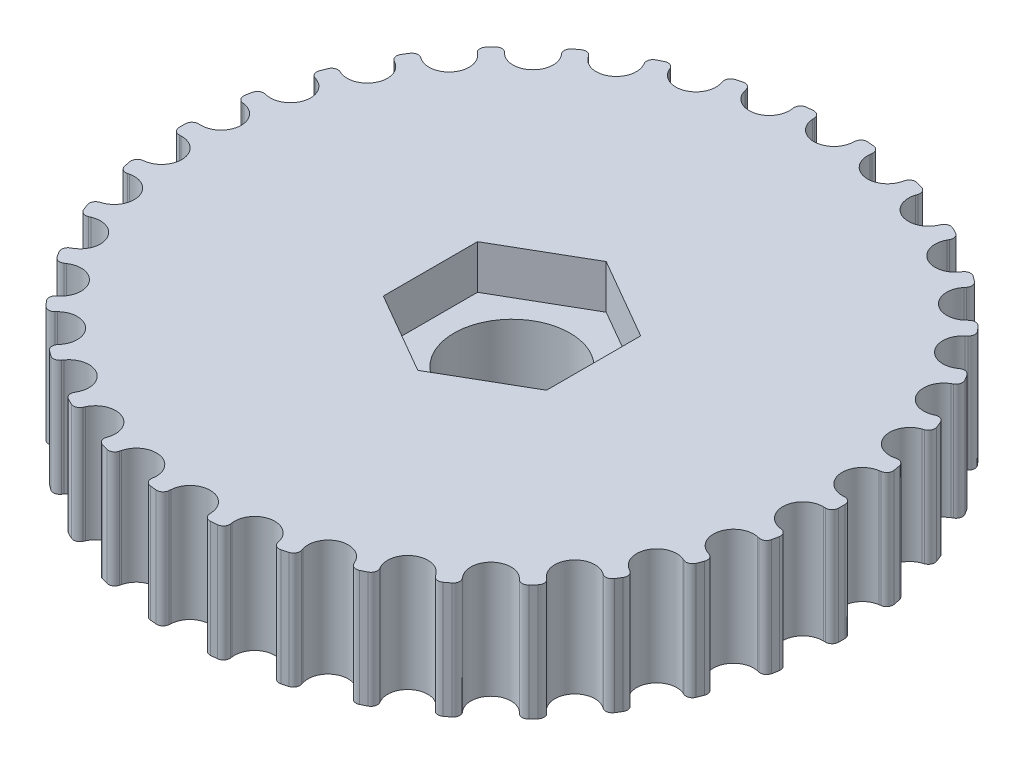
from build123d import *

# Parameters (mm, degrees)
SKETCH_1_R                       = 25.55
EXTRUDE_1_DEPTH                  = 9
SKETCH_2_R                       = 4.5
CUT_EXTRUDE_1_DEPTH              = 38.237145433
CUT_EXTRUDE_2_DEPTH              = 3.4
CUT_EXTRUDE_START                = -10
CUT_EXTRUDE_3_DEPTH              = 10
FILLET_1_R                       = 0.5
PATTERN_CIRCULAR_1_COUNT         = 34
FILLET_1_OF_PATTERN_CIRCULAR_1_R = 0.5


with BuildPart() as part:
    # Эскиз1 → Бобышка-Вытянуть1 (new body)
    with BuildSketch(Plane(origin=(0, 0, 0), x_dir=(1, 0, 0), z_dir=(0, 1, 0))):
        Circle(SKETCH_1_R)
    extrude(amount=EXTRUDE_1_DEPTH)

    # Эскиз2 → Вырез-Вытянуть1 (cut, through all)
    with BuildSketch(Plane(origin=(0, 9, 0), x_dir=(1, 0, 0), z_dir=(0, 1, 0))):
        Circle(SKETCH_2_R)
    extrude(amount=-CUT_EXTRUDE_1_DEPTH, mode=Mode.SUBTRACT)

    # Эскиз3 → Вырез-Вытянуть2 (cut)
    with BuildSketch(Plane(origin=(0, 9, 0), x_dir=(1, 0, 0), z_dir=(0, 1, 0))):
        Polygon((0, 7.3), (-6.321985448, 3.65), (-6.321985448, -3.65), (0, -7.3), (6.321985448, -3.65), (6.321985448, 3.65), align=None)
    extrude(amount=-CUT_EXTRUDE_2_DEPTH, mode=Mode.SUBTRACT)

    # Эскиз4 → Вырез-Вытянуть3 (cut)
    with BuildSketch(Plane(origin=(0, 9, 0), x_dir=(1, 0, 0), z_dir=(0, 1, 0)).offset(CUT_EXTRUDE_START)):
        with BuildLine():
            Line((-1.59751503, 25.50000874), (-1.556947692, 24.852460858))
            ThreePointArc((-1.556947692, 24.852460858), (-3e-09, 23.39), (1.556947692, 24.852460853))
            Line((1.556947692, 24.852460853), (1.59751503, 25.50000874))
            ThreePointArc((1.59751503, 25.50000874), (0, 25.55), (-1.59751503, 25.50000874))
        make_face()
    cut_extrude_3 = extrude(amount=CUT_EXTRUDE_3_DEPTH, mode=Mode.SUBTRACT)

    # Скругление1
    fillet_1_edges = [part.edges().sort_by_distance(p)[0] for p in [
        (-1.59751503, 4.5, -25.50000874),
        (1.59751503, 4.5, -25.50000874),
    ]]
    fillet(fillet_1_edges, radius=FILLET_1_R)

    # Круговой массив1: Вырез-Вытянуть3 ×34 about axis
    pattern_circular_1_axis = Axis((0, 0, 0), (0, 1, 0))
    for i in range(1, PATTERN_CIRCULAR_1_COUNT):
        add(cut_extrude_3.rotate(pattern_circular_1_axis, i * 360 / PATTERN_CIRCULAR_1_COUNT), mode=Mode.SUBTRACT)

    # Скругление1 of Круговой массив1
    fillet_1_of_pattern_circular_1_edges = [part.edges().sort_by_distance(p)[0] for p in [
        (-6.255928611, 4.5, -24.772280016),
        (-3.115300009, 4.5, -25.359365249),
        (-10.701304047, 4.5, -23.200961008),
        (-7.722027243, 4.5, -24.355138991),
        (-14.782259407, 4.5, -20.839561099),
        (-12.065790101, 4.5, -22.521527684),
        (-18.359822654, 4.5, -17.768494931),
        (-15.998666948, 4.5, -19.920972764),
        (-21.312164159, 4.5, -14.09234398),
        (-19.386728381, 4.5, -16.642033009),
        (-23.538745476, 4.5, -9.936295156),
        (-22.11459803, 4.5, -12.79636878),
        (-24.963743047, 4.5, -5.441877717),
        (-24.089381567, 4.5, -8.51493956),
        (-25.538630289, 4.5, -0.76214366),
        (-25.243830107, 4.5, -3.943544285),
        (-25.243830107, 4.5, 3.943544285),
        (-25.538630289, 4.5, 0.76214366),
        (-24.089381567, 4.5, 8.51493956),
        (-24.963743047, 4.5, 5.441877717),
        (-22.11459803, 4.5, 12.79636878),
        (-23.538745476, 4.5, 9.936295156),
        (-19.386728381, 4.5, 16.642033009),
        (-21.312164159, 4.5, 14.09234398),
        (-15.998666948, 4.5, 19.920972764),
        (-18.359822654, 4.5, 17.768494931),
        (-12.065790101, 4.5, 22.521527684),
        (-14.782259407, 4.5, 20.839561099),
        (-7.722027243, 4.5, 24.355138991),
        (-10.701304047, 4.5, 23.200961008),
        (-3.115300009, 4.5, 25.359365249),
        (-6.255928611, 4.5, 24.772280016),
        (1.59751503, 4.5, 25.50000874),
        (-1.59751503, 4.5, 25.50000874),
        (6.255928611, 4.5, 24.772280016),
        (3.115300009, 4.5, 25.359365249),
        (10.701304047, 4.5, 23.200961008),
        (7.722027243, 4.5, 24.355138991),
        (14.782259407, 4.5, 20.839561099),
        (12.065790101, 4.5, 22.521527684),
        (18.359822654, 4.5, 17.768494931),
        (15.998666948, 4.5, 19.920972764),
        (21.312164159, 4.5, 14.09234398),
        (19.386728381, 4.5, 16.642033009),
        (23.538745476, 4.5, 9.936295156),
        (22.11459803, 4.5, 12.79636878),
        (24.963743047, 4.5, 5.441877717),
        (24.089381567, 4.5, 8.51493956),
        (25.538630289, 4.5, 0.76214366),
        (25.243830107, 4.5, 3.943544285),
        (25.243830107, 4.5, -3.943544285),
        (25.538630289, 4.5, -0.76214366),
        (24.089381567, 4.5, -8.51493956),
        (24.963743047, 4.5, -5.441877717),
        (22.11459803, 4.5, -12.79636878),
        (23.538745476, 4.5, -9.936295156),
        (19.386728381, 4.5, -16.642033009),
        (21.312164159, 4.5, -14.09234398),
        (15.998666948, 4.5, -19.920972764),
        (18.359822654, 4.5, -17.768494931),
        (12.065790101, 4.5, -22.521527684),
        (14.782259407, 4.5, -20.839561099),
        (7.722027243, 4.5, -24.355138991),
        (10.701304047, 4.5, -23.200961008),
        (3.115300009, 4.5, -25.359365249),
        (6.255928611, 4.5, -24.772280016),
    ]]
    fillet(fillet_1_of_pattern_circular_1_edges, radius=FILLET_1_OF_PATTERN_CIRCULAR_1_R)


solid = part.part
